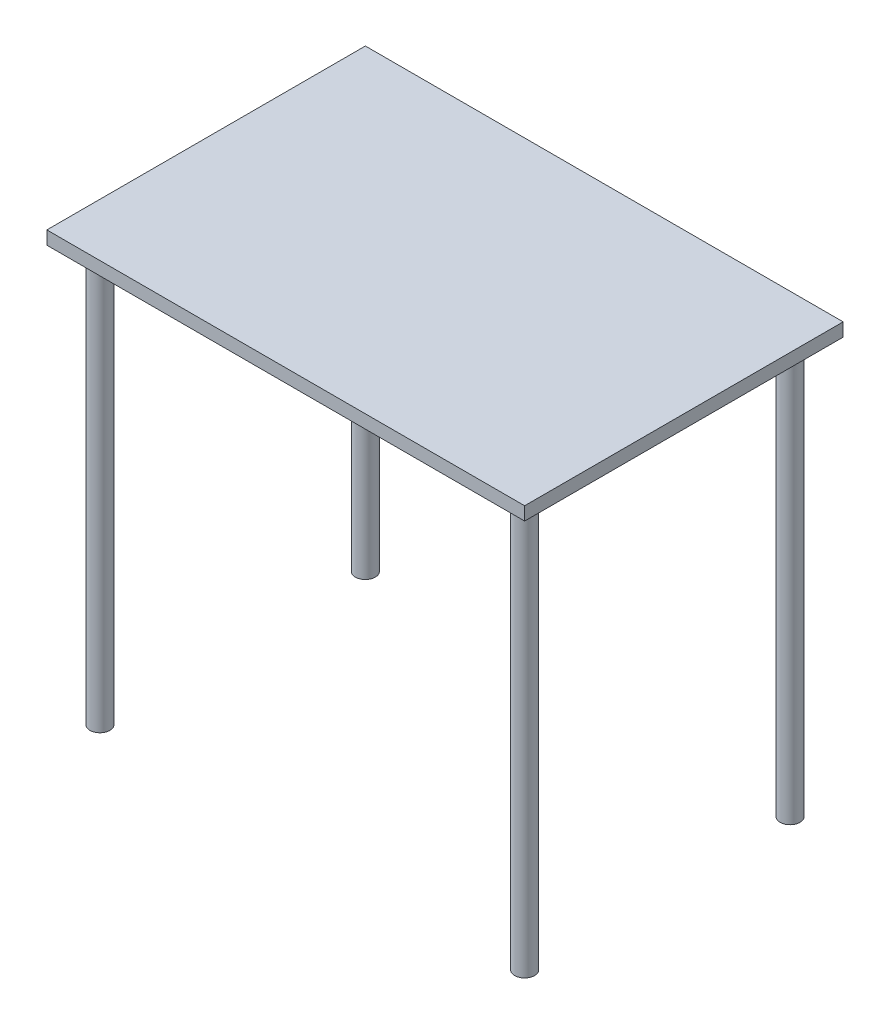
from build123d import *

# Parameters (mm, degrees)
SKETCH3_W   = 914.4
SKETCH3_H   = 609.6
TABLE_DEPTH = 25.4
SKETCH4_R   = 19.05
LEGS_DEPTH  = 794.675


with BuildPart() as part:
    # Sketch3 → Table (new body)
    with BuildSketch(Plane(origin=(0, 0, 0), x_dir=(1, 0, 0), z_dir=(0, 1, 0))):
        with Locations((457.2, 304.8)):
            Rectangle(SKETCH3_W, SKETCH3_H)
    extrude(amount=TABLE_DEPTH)

    # Sketch4 → Legs (add)
    with BuildSketch(Plane.XZ):
        with Locations((50.8, -50.8)):
            Circle(SKETCH4_R)
        with Locations((863.6, -50.8)):
            Circle(SKETCH4_R)
        with Locations((50.8, -558.8)):
            Circle(SKETCH4_R)
        with Locations((863.6, -558.8)):
            Circle(SKETCH4_R)
    extrude(amount=LEGS_DEPTH)


solid = part.part
